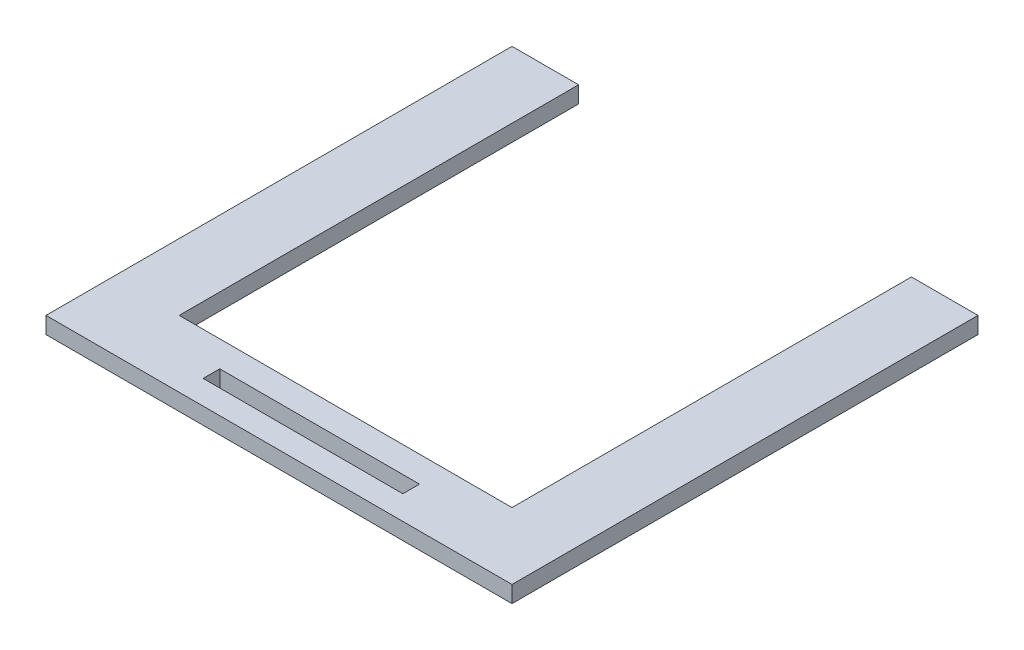
from build123d import *

# Parameters (mm, degrees)
BOSS_EXTRUDE1_DEPTH = 3.175
SKETCH3_W           = 38.1
SKETCH3_H           = 3.175
CUT_EXTRUDE1_DEPTH  = 3.175


with BuildPart() as part:
    # Sketch2 → Boss-Extrude1 (new body)
    with BuildSketch(Plane(origin=(0, 0, 0), x_dir=(1, 0, 0), z_dir=(0, 1, 0))):
        Polygon((-44.199800383, 37.887467748), (-31.499800383, 37.887467748), (-31.499800383, -38.312532252), (32.000199617, -38.312532252), (32.000199617, 37.887467748), (44.700199617, 37.887467748), (44.700199617, -38.312532252), (44.700199617, -51.012532252), (-44.199800383, -51.012532252), (-44.199800383, -38.312532252), align=None)
    extrude(amount=BOSS_EXTRUDE1_DEPTH)

    # Sketch3 → Cut-Extrude1 (cut)
    with BuildSketch(Plane(origin=(0, 3.175, 0), x_dir=(1, 0, 0), z_dir=(0, 1, 0))):
        with Locations((0.250199617, -44.853032252)):
            Rectangle(SKETCH3_W, SKETCH3_H)
    extrude(amount=-CUT_EXTRUDE1_DEPTH, mode=Mode.SUBTRACT)


solid = part.part
